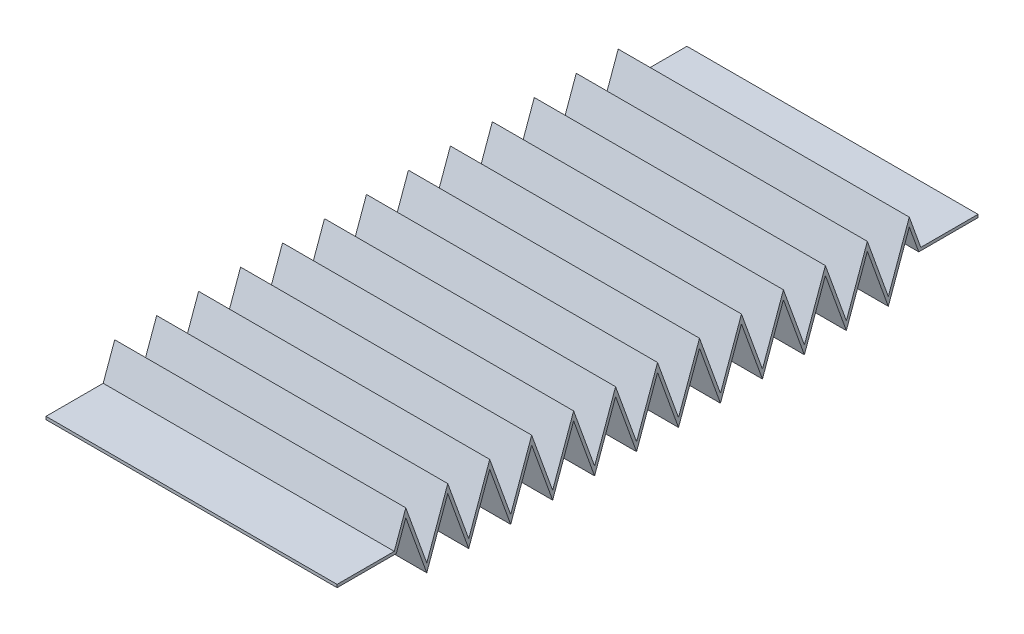
from build123d import *

# Parameters (mm, degrees)
EXTRUDE_THIN1_DEPTH = 25


with BuildPart() as part:
    # Sketch3 → Extrude-Thin1 (new body, symmetric)
    with BuildSketch(Plane(origin=(0, 0, 0), x_dir=(0, 0, -1), z_dir=(1, 0, 0))):
        Polygon((0, 4.75), (10.175645864, 4.75), (11.801837516, 9.26259239), (15.405512547, -0.73740761), (19.009187578, 9.26259239), (22.612862609, -0.73740761), (26.21653764, 9.26259239), (29.820212671, -0.73740761), (33.423887702, 9.26259239), (37.027562733, -0.73740761), (40.631237764, 9.26259239), (44.234912795, -0.73740761), (47.838587827, 9.26259239), (51.442262858, -0.73740761), (55.045937889, 9.26259239), (58.64961292, -0.73740761), (62.253287951, 9.26259239), (65.856962982, -0.73740761), (69.460638013, 9.26259239), (73.064313044, -0.73740761), (76.667988075, 9.26259239), (80.271663106, -0.73740761), (83.875338138, 9.26259239), (87.479013169, -0.73740761), (91.0826882, 9.26259239), (94.686363231, -0.73740761), (98.290038262, 9.26259239), (99.916229914, 4.75), (110.091875777, 4.75), (110.091875777, 5.25), (100.267521641, 5.25), (98.290038262, 10.73740761), (94.686363231, 0.73740761), (91.0826882, 10.73740761), (87.479013169, 0.73740761), (83.875338138, 10.73740761), (80.271663106, 0.73740761), (76.667988075, 10.73740761), (73.064313044, 0.73740761), (69.460638013, 10.73740761), (65.856962982, 0.73740761), (62.253287951, 10.73740761), (58.64961292, 0.73740761), (55.045937889, 10.73740761), (51.442262858, 0.73740761), (47.838587827, 10.73740761), (44.234912795, 0.73740761), (40.631237764, 10.73740761), (37.027562733, 0.73740761), (33.423887702, 10.73740761), (29.820212671, 0.73740761), (26.21653764, 10.73740761), (22.612862609, 0.73740761), (19.009187578, 10.73740761), (15.405512547, 0.73740761), (11.801837516, 10.73740761), (9.824354136, 5.25), (0, 5.25), align=None)
    extrude(amount=EXTRUDE_THIN1_DEPTH, both=True)


solid = part.part
